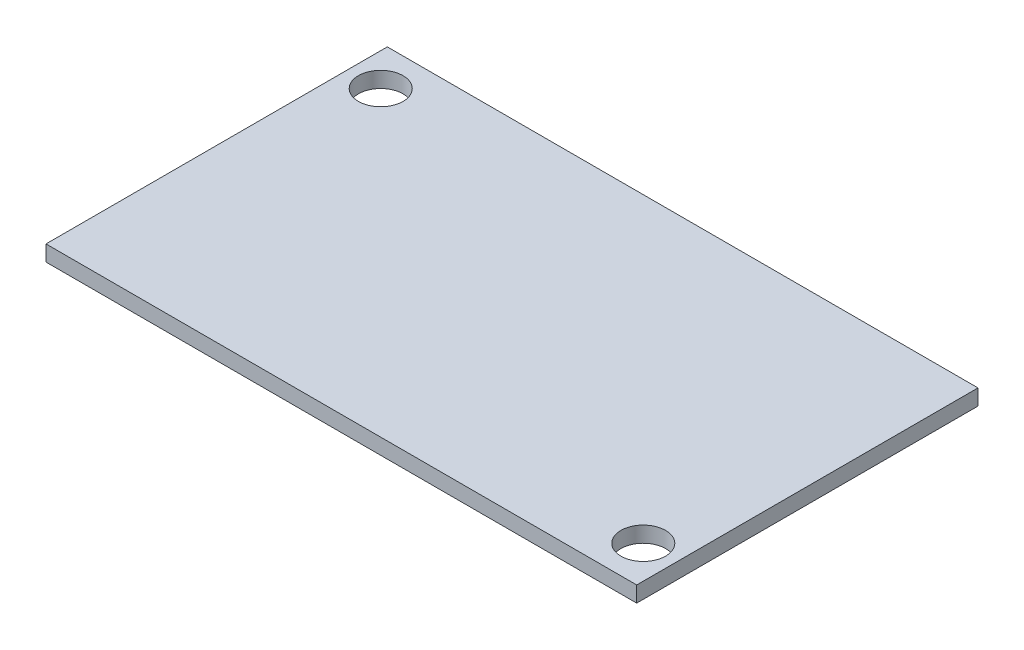
from build123d import *

# Parameters (mm, degrees)
SKETCH1_W            = 45
SKETCH1_H            = 26
BOSS_EXTRUDE1_DEPTH  = 1.2
M3_CLEARANCE_HOLE1_D = 3.4


with BuildPart() as part:
    # Sketch1 → Boss-Extrude1 (new body)
    with BuildSketch(Plane(origin=(0, 0, 0), x_dir=(1, 0, 0), z_dir=(0, 1, 0))):
        with Locations((-2.277491725, -11.641351661)):
            Rectangle(SKETCH1_W, SKETCH1_H)
    extrude(amount=BOSS_EXTRUDE1_DEPTH)

    # M3 Clearance Hole1 (through all)
    with Locations(Plane(origin=(-22.277491725, 1.2, 1.641351661), x_dir=(0, 0, 1), z_dir=(0, 1, 0))):
        with Locations((0, 0), (20, 40)):
            Hole(M3_CLEARANCE_HOLE1_D / 2)


solid = part.part
